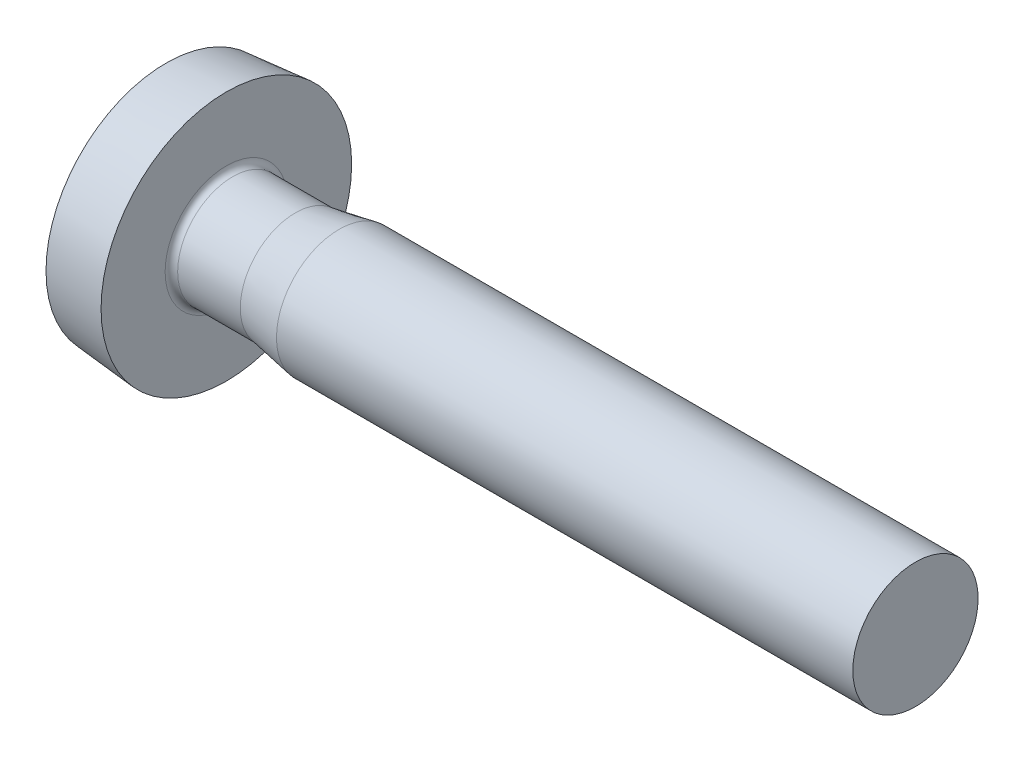
from build123d import *

# Parameters (mm, degrees)
CUT_EXTRUDE1_DEPTH = 0.8


with BuildPart() as part:
    # Sketch1 → Revolve1 (revolve)
    with BuildSketch(Plane.XY):
        with BuildLine():
            Line((-0.963195994, 1.91573127), (0, 2))
            Line((0, 2), (0, 0.87725))
            Line((0, 0.87725), (1.1, 0.87725))
            Line((1.1, 0.87725), (1.8, 1))
            Line((1.8, 1), (11, 1))
            Line((11, 1), (11, 0))
            Line((11, 0), (-1.6, 0))
            ThreePointArc((-1.6, 0), (-1.436628655, 1.009399034), (-0.963195994, 1.91573127))
        make_face()
    revolve(axis=Axis((11, 0, 0), (-1, 0, 0)))

    # Sketch2 → Revolve2 (revolve)
    with BuildSketch(Plane.XY):
        with BuildLine():
            Line((-0.1, 0.77725), (1.1, 0.77725))
            Line((1.1, 0.77725), (1.1, 0.87725))
            Line((1.1, 0.87725), (0.1, 0.87725))
            ThreePointArc((0.1, 0.87725), (0.029289322, 0.906539322), (0, 0.97725))
            Line((0, 0.97725), (-0.1, 0.97725))
            Line((-0.1, 0.97725), (-0.1, 0.77725))
        make_face()
    revolve(axis=Axis((1.1, 0, 0), (-1, 0, 0)))

    # Sketch3 → Cut-Extrude1 (cut)
    with BuildSketch(Plane(origin=(-1.6, 0, 0), x_dir=(0, 0, -1), z_dir=(1, 0, 0))):
        Polygon((-0.95, 0.2375), (-0.95, -0.2375), (-0.38, -0.187631462), (-0.2375, -0.2375), (-0.187631462, -0.38), (-0.2375, -0.95), (0.2375, -0.95), (0.187631462, -0.38), (0.2375, -0.2375), (0.38, -0.187631462), (0.95, -0.2375), (0.95, 0.2375), (0.38, 0.187631462), (0.2375, 0.2375), (0.187631462, 0.38), (0.2375, 0.95), (-0.2375, 0.95), (-0.187631462, 0.38), (-0.2375, 0.2375), (-0.38, 0.187631462), align=None)
    extrude(amount=CUT_EXTRUDE1_DEPTH, mode=Mode.SUBTRACT)


solid = part.part
